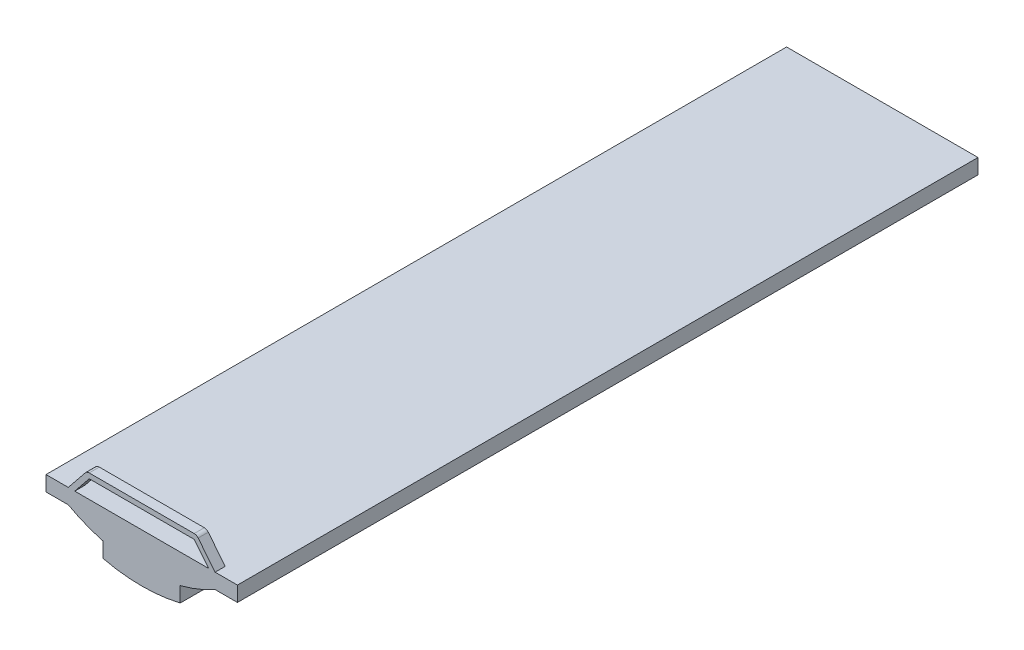
from build123d import *

# Parameters (mm, degrees)
BOSS_EXTRUDE1_DEPTH = 220
BOSS_EXTRUDE2_DEPTH = 3
FILLET1_R           = 1.5
SCALE1_SCALE        = 15.6
SCALE2_SCALE        = 0.5


with BuildPart() as part:
    # Sketch1 → Boss-Extrude1 (new body)
    with BuildSketch(Plane.XY):
        with BuildLine():
            Line((0, 0), (0, -4.480629882))
            Line((0, -4.480629882), (6.620887994, -4.480629882))
            ThreePointArc((6.620887994, -4.480629882), (11.673872347, -6.882935474), (16.9859081, -8.639636697))
            Line((16.9859081, -8.639636697), (16.9859081, -13.120266579))
            ThreePointArc((16.9859081, -13.120266579), (28.43159427, -14.466004542), (39.877280439, -13.120266579))
            Line((39.877280439, -13.120266579), (39.877280439, -8.639636697))
            ThreePointArc((39.877280439, -8.639636697), (45.189316192, -6.882935474), (50.242300545, -4.480629882))
            Line((50.242300545, -4.480629882), (56.863188539, -4.480629882))
            Line((56.863188539, -4.480629882), (56.863188539, 0))
            Line((56.863188539, 0), (0, 0))
        make_face()
    extrude(amount=BOSS_EXTRUDE1_DEPTH)

    # Sketch2 → Boss-Extrude2 (add)
    with BuildSketch(Plane.XY.offset(220)):
        Polygon((6.620887994, 0), (12.113374984, 6.832485321), (44.749813555, 6.832485321), (50.242300545, 0), (48.317723739, 0), (44.031054266, 5.332485321), (12.832134273, 5.332485321), (8.545464801, 0), align=None)
    extrude(amount=-BOSS_EXTRUDE2_DEPTH)

    # Fillet1
    fillet1_edges = [part.edges().sort_by_distance(p)[0] for p in [
        (12.113374984, 6.832485321, 218.5),
        (44.749813555, 6.832485321, 218.5),
    ]]
    fillet(fillet1_edges, radius=FILLET1_R)


with BuildPart() as part_1:
    # Scale1: scaled about (28.43159427, -5.503767505, 110.201488626)
    add(part.part.scale(SCALE1_SCALE).moved(Location((-415.101276342, 80.355005573, -1608.94173394))))


with BuildPart() as part_2:
    # Scale2: scaled about (28.431594264, -5.503767501, 110.201488629)
    add(part_1.part.scale(SCALE2_SCALE).moved(Location((14.215797132, -2.75188375, 55.100744314))))


solid = part_2.part
